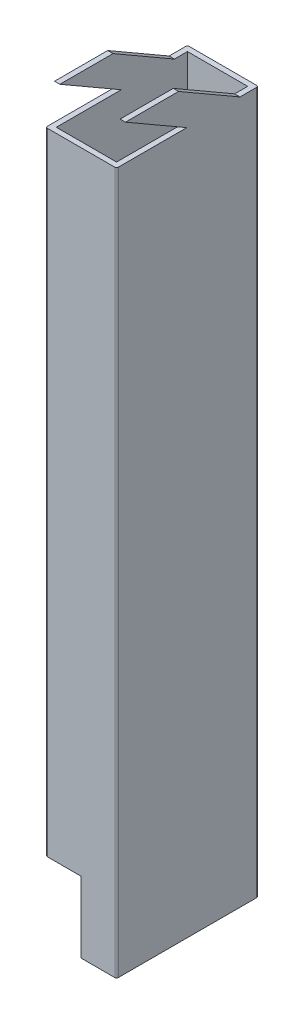
from build123d import *

# Parameters (mm, degrees)
SKETCH1_W           = 17
SKETCH1_H           = 37
BOSS_EXTRUDE1_DEPTH = 208
SKETCH2_W           = 10
SKETCH2_H           = 20
CUT_EXTRUDE1_DEPTH  = 40
CUT_EXTRUDE2_DEPTH  = 40


with BuildPart() as part:
    # Sketch1 → Boss-Extrude1 (new body)
    with BuildSketch(Plane(origin=(0, 0, 0), x_dir=(1, 0, 0), z_dir=(0, 1, 0))):
        with BuildLine():
            Line((0.5, 0), (19.5, 0))
            ThreePointArc((19.5, 0), (19.853553391, 0.146446609), (20, 0.5))
            Line((20, 0.5), (20, 39.5))
            ThreePointArc((20, 39.5), (19.853553391, 39.853553391), (19.5, 40))
            Line((19.5, 40), (0.5, 40))
            ThreePointArc((0.5, 40), (0.146446609, 39.853553391), (0, 39.5))
            Line((0, 39.5), (0, 0.5))
            ThreePointArc((0, 0.5), (0.146446609, 0.146446609), (0.5, 0))
        make_face()
        with Locations((10, 20)):
            Rectangle(SKETCH1_W, SKETCH1_H, mode=Mode.SUBTRACT)
    extrude(amount=BOSS_EXTRUDE1_DEPTH)

    # Sketch2 → Cut-Extrude1 (cut)
    with BuildSketch(Plane.XY):
        with Locations((5, 10)):
            Rectangle(SKETCH2_W, SKETCH2_H)
    extrude(amount=-CUT_EXTRUDE1_DEPTH, mode=Mode.SUBTRACT)

    # Sketch3 → Cut-Extrude2 (cut)
    with BuildSketch(Plane(origin=(0, 0, 0), x_dir=(0, 0, -1), z_dir=(1, 0, 0))):
        Polygon((0, 208), (0, 198), (19.820508076, 198), (2.5, 208), align=None)
        Polygon((17.5, 208), (34.820508076, 198), (40, 198), (40, 208), align=None)
    extrude(amount=CUT_EXTRUDE2_DEPTH, mode=Mode.SUBTRACT)


solid = part.part
